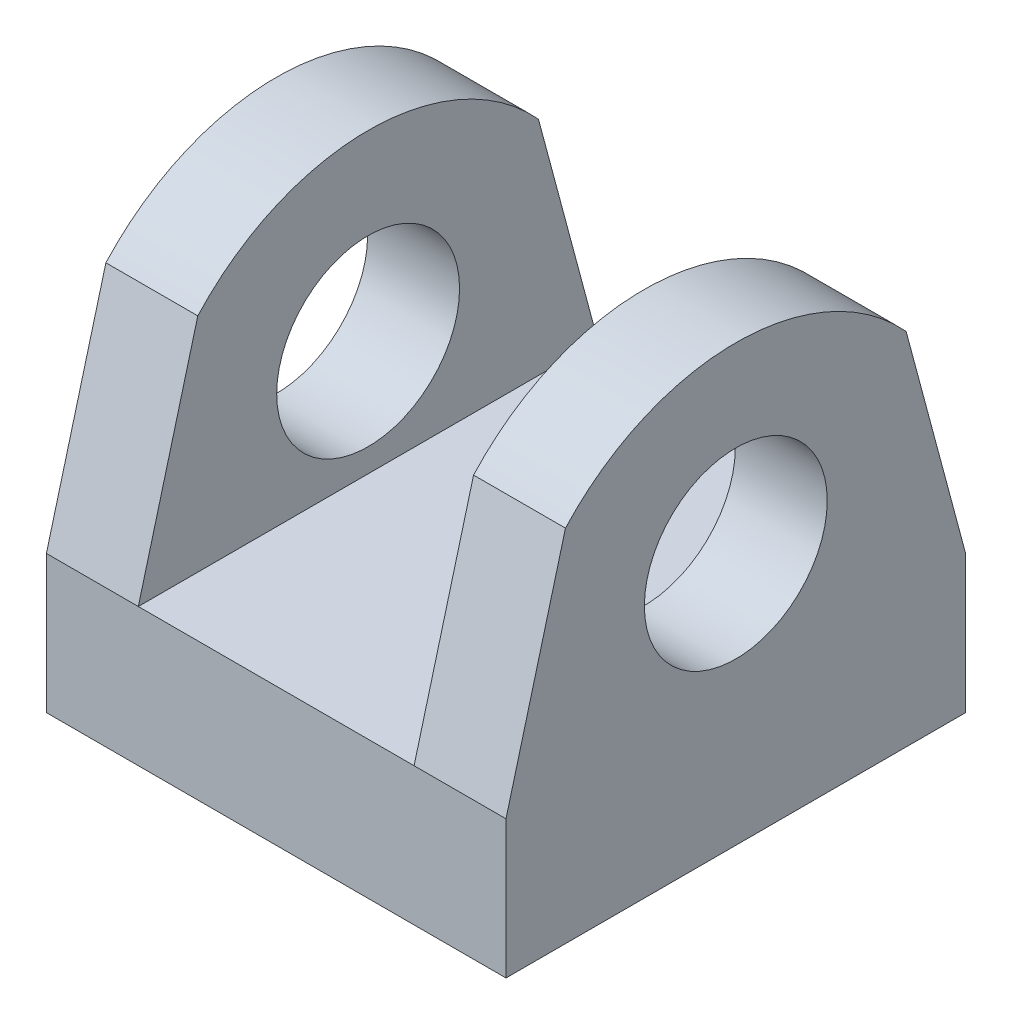
from build123d import *

# Parameters (mm, degrees)
SKETCH1_W           = 25.4
SKETCH1_H           = 25.4
BOSS_EXTRUDE1_DEPTH = 7.62
BOSS_EXTRUDE2_DEPTH = 5.08
SKETCH3_R           = 5.053169443
CUT_EXTRUDE1_DEPTH  = 26.4


with BuildPart() as part:
    # Sketch1 → Boss-Extrude1 (new body)
    with BuildSketch(Plane(origin=(0, 0, 0), x_dir=(1, 0, 0), z_dir=(0, 1, 0))):
        Rectangle(SKETCH1_W, SKETCH1_H)
    extrude(amount=BOSS_EXTRUDE1_DEPTH)

    # Sketch2 → Boss-Extrude2 (add)
    with BuildSketch(Plane(origin=(12.7, 0, 0), x_dir=(0, 0, -1), z_dir=(1, 0, 0))):
        with BuildLine():
            Line((-12.7, 7.62), (-9.412998127, 19.887257994))
            ThreePointArc((-9.412998127, 19.887257994), (0, 24.05658338), (9.412998127, 19.887257994))
            Line((9.412998127, 19.887257994), (12.7, 7.62))
            Line((12.7, 7.62), (-12.7, 7.62))
        make_face()
    boss_extrude2 = extrude(amount=-BOSS_EXTRUDE2_DEPTH)

    # Mirror1: Boss-Extrude2 across plane
    add(boss_extrude2.mirror(Plane(origin=(0, 0, 0), x_dir=(0, 0, 1), z_dir=(1, 0, 0))))

    # Sketch3 → Cut-Extrude1 (cut, through all)
    with BuildSketch(Plane(origin=(12.7, 0, 0), x_dir=(0, 0, -1), z_dir=(1, 0, 0))):
        with Locations((0, 13.97)):
            Circle(SKETCH3_R)
    extrude(amount=-CUT_EXTRUDE1_DEPTH, mode=Mode.SUBTRACT)


solid = part.part
